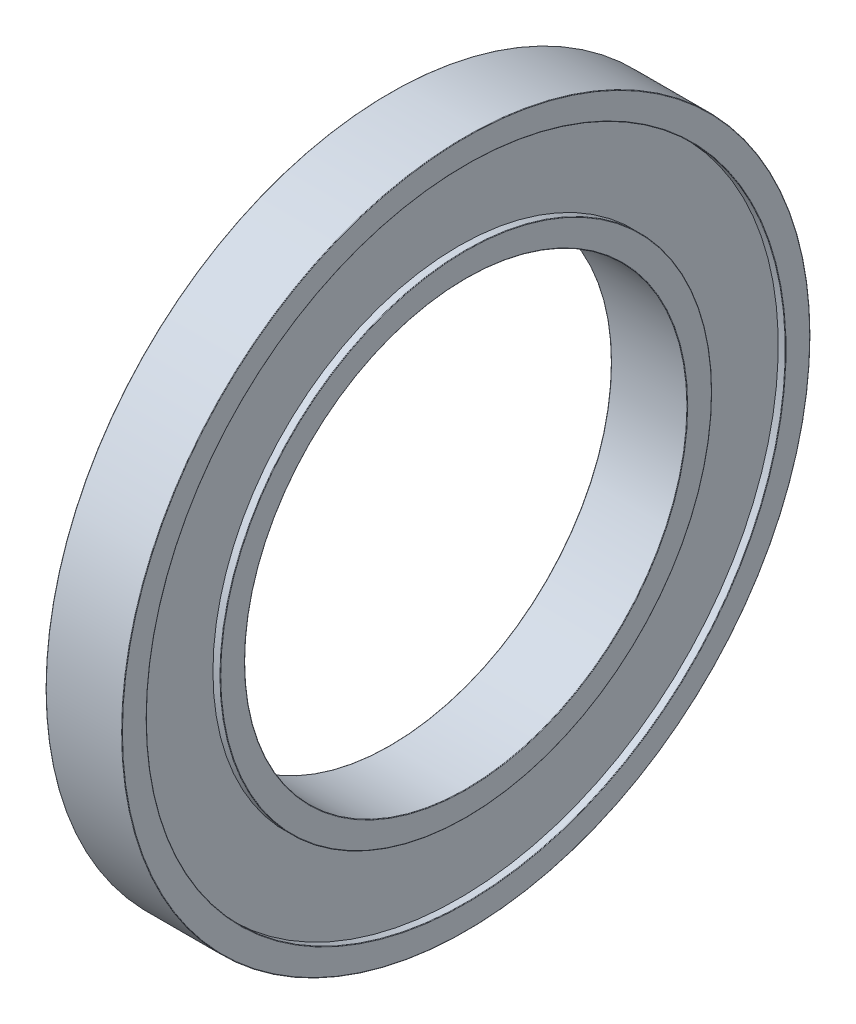
from build123d import *

# Parameters (mm, degrees)
VERRUNDUNG1_R = 0.2


with BuildPart() as part:
    # Skizze1 → Rotation1 (revolve)
    with BuildSketch(Plane.XY, mode=Mode.PRIVATE) as rotation1_sk:
        Polygon((0, 130), (0, 140), (31, 140), (31, 130), (28, 130), (28, 100), (31, 100), (31, 90), (0, 90), (0, 100), (3, 100), (3, 130), align=None)
    revolve(rotation1_sk.sketch.rotate(Axis((0, 0, 0), (1, 0, 0)), 90), axis=Axis((0, 0, 0), (1, 0, 0)))  # turned: the seam where the file's is

    # Verrundung1
    verrundung1_edges = [part.edges().sort_by_distance(p)[0] for p in [
        (0, 0, -130),
        (0, 0, -140),
        (31, 0, -140),
        (31, 0, -130),
        (31, 0, -100),
        (31, 0, -90),
        (0, 0, -90),
        (0, 0, -100),
    ]]
    fillet(verrundung1_edges, radius=VERRUNDUNG1_R)


solid = part.part
